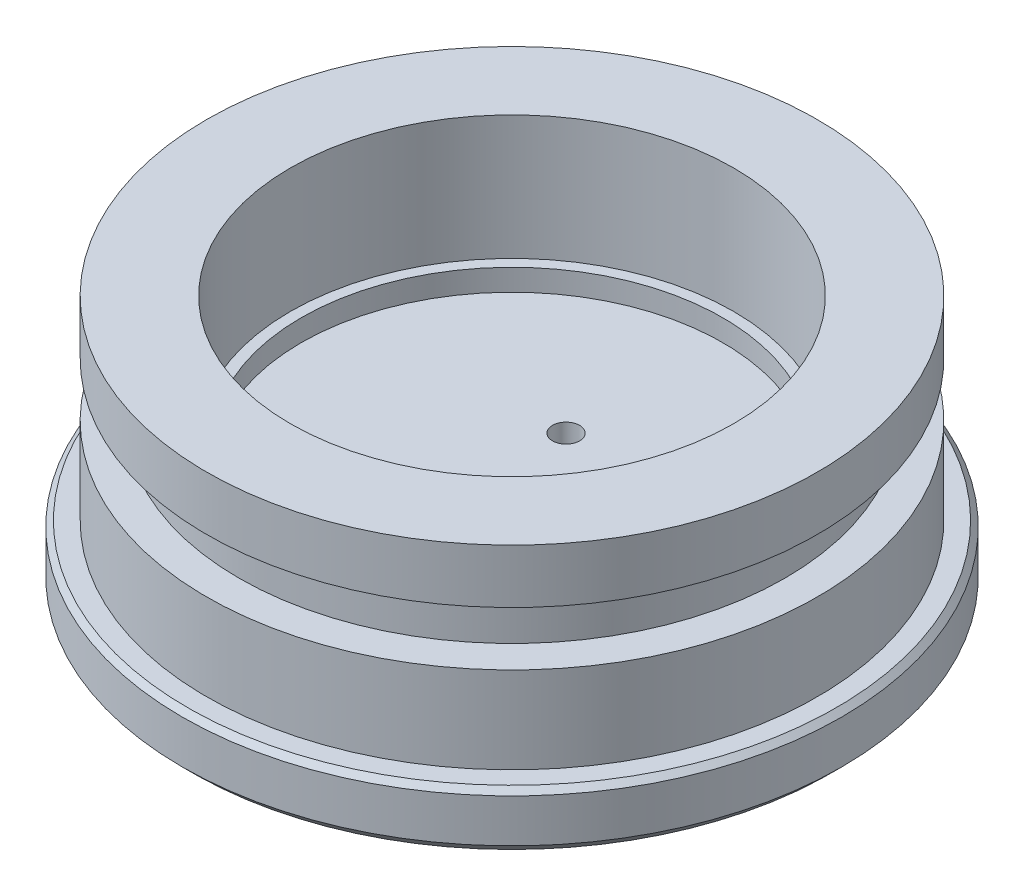
from build123d import *

# Parameters (mm, degrees)
M3X0_51_D     = 2.5
M3X0_51_DEPTH = 7
M3X0_51_TIP   = 0.751075774


with BuildPart() as part:
    # Эскиз1 → Повернуть1 (revolve)
    with BuildSketch(Plane.XY):
        Polygon((0, 0), (-29.5, 0), (-30.5, 1), (-30.5, 5), (-30, 5.5), (-28.25, 5.5), (-28.25, 13.5), (-25.25, 13.5), (-25.25, 18.5), (-28.25, 18.5), (-28.25, 23.5), (-20.5, 23.5), (-20.5, 12), (-19.5, 12), (-19.5, 10), (0, 10), align=None)
    revolve(axis=Axis((0, 10, 0), (0, -1, 0)))

    # Отверстие обработанное метчиком M3x0.51
    with Locations(Plane(origin=(0, 10, -5), x_dir=(1, 0, 0), z_dir=(0, 1, 0))):
        with Locations((0, 0)):
            Hole(M3X0_51_D / 2, depth=M3X0_51_DEPTH)
            with Locations((0, 0, -(M3X0_51_DEPTH + M3X0_51_TIP / 2))):  # 118° drill point
                Cone(0, M3X0_51_D / 2, M3X0_51_TIP, mode=Mode.SUBTRACT)


solid = part.part
